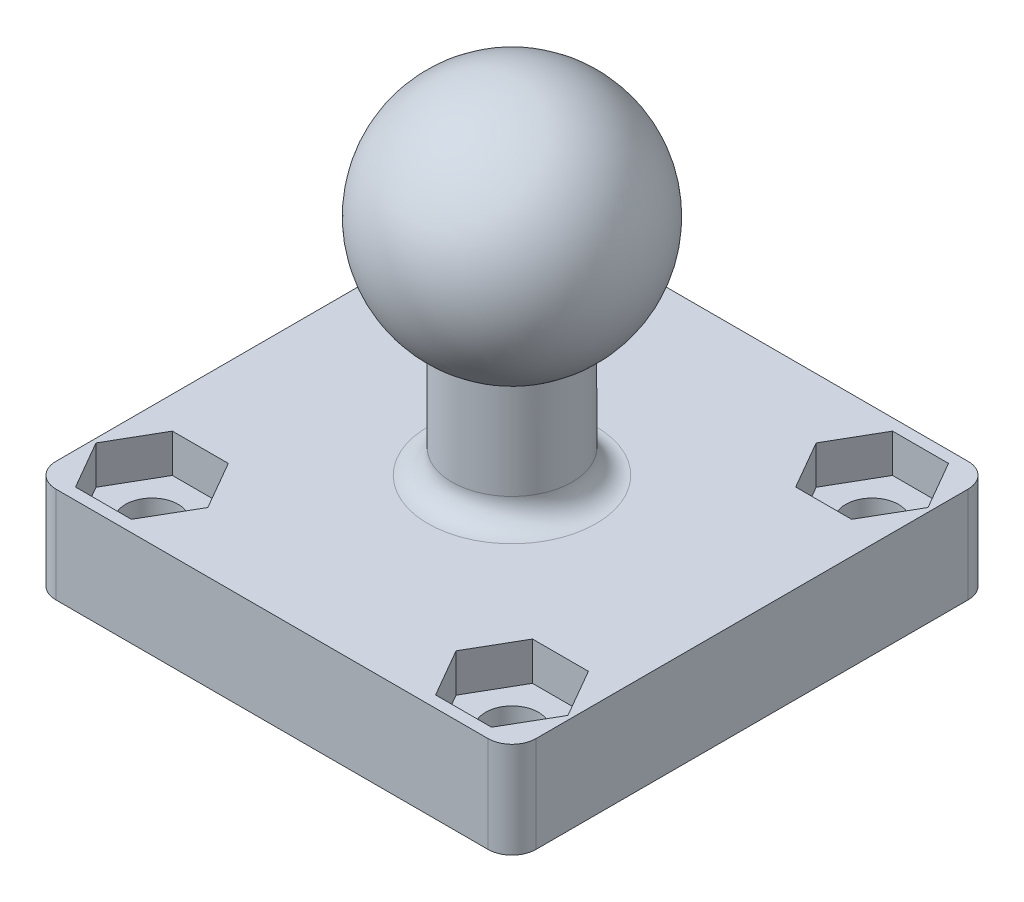
from build123d import *

# Parameters (mm, degrees)
ESQUISSE2_W             = 20
ESQUISSE2_H             = 20
BOSS_EXTRU_1_DEPTH      = 4
ENL_V_MAT_EXTRU_1_REACH = 6
ESQUISSE3_R             = 1.1
CONG_1_R                = 1
ENL_V_MAT_EXTRU_2_DEPTH = 1.6


with BuildPart() as part:
    # Esquisse1 → Révolution1 (revolve)
    with BuildSketch(Plane.XY):
        with BuildLine():
            Line((-2.5, -4.330127019), (-2.5, -9.330127019))
            Line((-2.5, -9.330127019), (0, -9.330127019))
            Line((0, -9.330127019), (0, 5))
            ThreePointArc((0, 5), (-4.829629131, 1.294095226), (-2.5, -4.330127019))
        make_face()
    revolve(axis=Axis((0, -9.330127019, 0), (0, 1, 0)))

    # Esquisse2 → Boss.-Extru.1 (add)
    with BuildSketch(Plane.XZ.offset(9.330127019)):
        Rectangle(ESQUISSE2_W, ESQUISSE2_H)
    extrude(amount=BOSS_EXTRU_1_DEPTH)

    # Esquisse3 → Enlèv. mat.-Extru.1 (cut, up to next)
    with BuildSketch(Plane(origin=(0, -9.330127019, 0), x_dir=(1, 0, 0), z_dir=(0, 1, 0)), mode=Mode.PRIVATE) as enl_v_mat_extru_1_sk1:
        with Locations(Location((7.5, -7.5, 0), (0, 0, 180))):  # turned: the seam where the file's is
            Circle(ESQUISSE3_R)
    enl_v_mat_extru_1_tool1 = extrude(enl_v_mat_extru_1_sk1.sketch, amount=-ENL_V_MAT_EXTRU_1_REACH, mode=Mode.PRIVATE) & part.part
    add(enl_v_mat_extru_1_tool1.solids().sort_by_distance((7.5, -9.330127, 7.5))[0], mode=Mode.SUBTRACT)
    # Esquisse3 → Enlèv. mat.-Extru.1 (cut, up to next)
    with BuildSketch(Plane(origin=(0, -9.330127019, 0), x_dir=(1, 0, 0), z_dir=(0, 1, 0)), mode=Mode.PRIVATE) as enl_v_mat_extru_1_sk2:
        with Locations(Location((7.5, 7.5, 0), (0, 0, 180))):  # turned: the seam where the file's is
            Circle(ESQUISSE3_R)
    enl_v_mat_extru_1_tool2 = extrude(enl_v_mat_extru_1_sk2.sketch, amount=-ENL_V_MAT_EXTRU_1_REACH, mode=Mode.PRIVATE) & part.part
    add(enl_v_mat_extru_1_tool2.solids().sort_by_distance((7.5, -9.330127, -7.5))[0], mode=Mode.SUBTRACT)
    # Esquisse3 → Enlèv. mat.-Extru.1 (cut, up to next)
    with BuildSketch(Plane(origin=(0, -9.330127019, 0), x_dir=(1, 0, 0), z_dir=(0, 1, 0)), mode=Mode.PRIVATE) as enl_v_mat_extru_1_sk3:
        with Locations(Location((-7.5, 7.5, 0), (0, 0, 180))):  # turned: the seam where the file's is
            Circle(ESQUISSE3_R)
    enl_v_mat_extru_1_tool3 = extrude(enl_v_mat_extru_1_sk3.sketch, amount=-ENL_V_MAT_EXTRU_1_REACH, mode=Mode.PRIVATE) & part.part
    add(enl_v_mat_extru_1_tool3.solids().sort_by_distance((-7.5, -9.330127, -7.5))[0], mode=Mode.SUBTRACT)
    # Esquisse3 → Enlèv. mat.-Extru.1 (cut, up to next)
    with BuildSketch(Plane(origin=(0, -9.330127019, 0), x_dir=(1, 0, 0), z_dir=(0, 1, 0)), mode=Mode.PRIVATE) as enl_v_mat_extru_1_sk4:
        with Locations(Location((-7.5, -7.5, 0), (0, 0, 180))):  # turned: the seam where the file's is
            Circle(ESQUISSE3_R)
    enl_v_mat_extru_1_tool4 = extrude(enl_v_mat_extru_1_sk4.sketch, amount=-ENL_V_MAT_EXTRU_1_REACH, mode=Mode.PRIVATE) & part.part
    add(enl_v_mat_extru_1_tool4.solids().sort_by_distance((-7.5, -9.330127, 7.5))[0], mode=Mode.SUBTRACT)

    # Congé1
    cong_1_edges = [part.edges().sort_by_distance(p)[0] for p in [
        (-10, -11.330127019, -10),
        (10, -11.330127019, -10),
        (10, -11.330127019, 10),
        (2.5, -9.330127019, 0),
        (-10, -11.330127019, 10),
    ]]
    fillet(cong_1_edges, radius=CONG_1_R)

    # Esquisse4 → Enlèv. mat.-Extru.2 (cut)
    with BuildSketch(Plane(origin=(0, -9.330127019, 0), x_dir=(1, 0, 0), z_dir=(0, 1, 0))):
        Polygon((-6.335, -5.482160809), (-8.665, -5.482160809), (-9.83, -7.5), (-8.665, -9.517839191), (-6.335, -9.517839191), (-5.17, -7.5), align=None)
        Polygon((9.83, -7.5), (8.665, -5.482160809), (6.335, -5.482160809), (5.17, -7.5), (6.335, -9.517839191), (8.665, -9.517839191), align=None)
        Polygon((8.665, 5.482160809), (9.83, 7.5), (8.665, 9.517839191), (6.335, 9.517839191), (5.17, 7.5), (6.335, 5.482160809), align=None)
        Polygon((-5.17, 7.5), (-6.335, 9.517839191), (-8.665, 9.517839191), (-9.83, 7.5), (-8.665, 5.482160809), (-6.335, 5.482160809), align=None)
    extrude(amount=-ENL_V_MAT_EXTRU_2_DEPTH, mode=Mode.SUBTRACT)


solid = part.part
